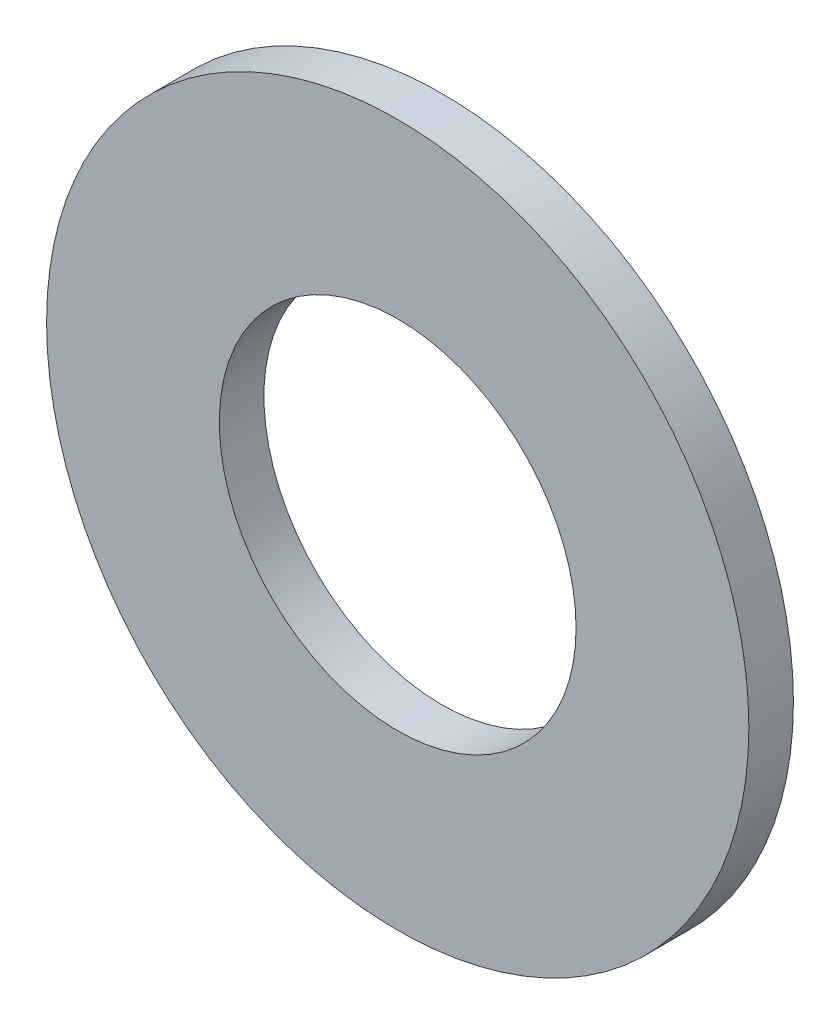
from build123d import *

# Parameters (mm, degrees)
SKETCH1_R           = 3.15
SKETCH1_R_2         = 1.6
BOSS_EXTRUDE1_DEPTH = 0.4


with BuildPart() as part:
    # Sketch1 → Boss-Extrude1 (new body)
    with BuildSketch(Plane(origin=(0, 0, 0), x_dir=(0, 1, 0), z_dir=(0, 0, 1))):
        Circle(SKETCH1_R)
        Circle(SKETCH1_R_2, mode=Mode.SUBTRACT)
    extrude(amount=BOSS_EXTRUDE1_DEPTH)


solid = part.part
